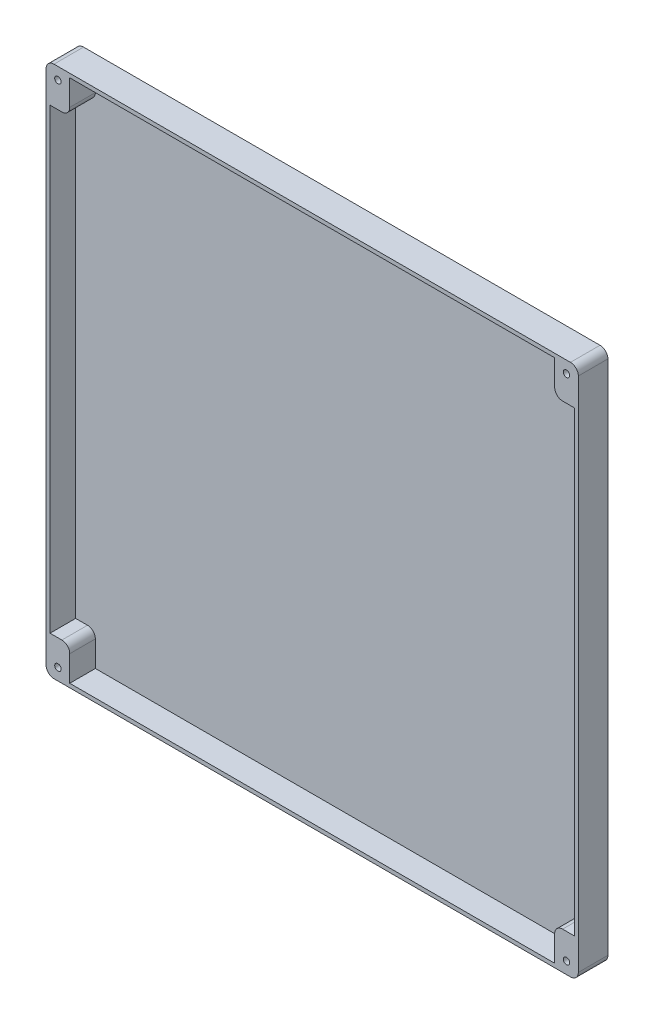
from build123d import *

# Parameters (mm, degrees)
ESQUISSE1_W                                  = 270
ESQUISSE1_H                                  = 270
EXTRUSION1_DEPTH                             = 15
CONG_2_R                                     = 4
EXTRUSION2_DEPTH                             = 13
CONG_3_R                                     = 4
CHAMBRAGE_POUR_VIS_T_TE_RONDE_BOMB_E_A_COUNT = 2
CHAMBRAGE_POUR_VIS_T_TE_RONDE_BOMB_E_A_PITCH = 258
CHAMBRAGE_POUR_VIS_T_TE_RONDE_BOMB_2_COUNT   = 2
CHAMBRAGE_POUR_VIS_T_TE_RONDE_BOMB_2_PITCH   = 364.867099092
CHAMBRAGE_POUR_VIS_T_TE_RONDE_BOMB_3_COUNT   = 2
CHAMBRAGE_POUR_VIS_T_TE_RONDE_BOMB_3_PITCH   = 258


with BuildPart() as part:
    # Esquisse1 → Extrusion1 (new body)
    with BuildSketch(Plane.XY):
        with Locations((135, -135)):
            Rectangle(ESQUISSE1_W, ESQUISSE1_H)
    extrude(amount=EXTRUSION1_DEPTH)

    # Congé2
    cong_2_edges = [part.edges().sort_by_distance(p)[0] for p in [
        (0, 0, 7.5),
        (270, 0, 7.5),
        (270, -270, 7.5),
        (0, -270, 7.5),
    ]]
    fillet(cong_2_edges, radius=CONG_2_R)

    # Esquisse2 → Extrusion2 (cut)
    with BuildSketch(Plane.XY.offset(15)):
        Polygon((12, -2), (12, -19), (2, -19), (2, -251), (12, -251), (12, -268), (258, -268), (258, -251), (268, -251), (268, -19), (258, -19), (258, -2), align=None)
    extrude(amount=-EXTRUSION2_DEPTH, mode=Mode.SUBTRACT)

    # Congé3
    cong_3_edges = [part.edges().sort_by_distance(p)[0] for p in [
        (258, -19, 8.5),
        (258, -251, 8.5),
        (12, -251, 8.5),
        (12, -19, 8.5),
    ]]
    fillet(cong_3_edges, radius=CONG_3_R)

    # Esquisse6 → Chambrage pour vis à tête ronde bombée #41 (revolve, cut)
    with BuildSketch(Plane(origin=(264, -6, 0), x_dir=(0, 1, 0), z_dir=(1, 0, 0))):
        Polygon((0, 0), (0, 15), (1.63195, 15), (1.63195, 4.031996), (3.175, 4.031996), (3.175, 0.635), (3.81, 0), align=None)
    chambrage_pour_vis_t_te_ronde_bomb_e = revolve(axis=Axis((264, -6, -6.35), (0, 0, 1)), mode=Mode.SUBTRACT)

    # Chambrage pour vis à tête ronde bombée #41 a: Chambrage pour vis à tête ronde bombée #41 ×2
    with Locations(*[(-i * CHAMBRAGE_POUR_VIS_T_TE_RONDE_BOMB_E_A_PITCH, 0, 0) for i in range(1, CHAMBRAGE_POUR_VIS_T_TE_RONDE_BOMB_E_A_COUNT)]):
        add(chambrage_pour_vis_t_te_ronde_bomb_e, mode=Mode.SUBTRACT)

    # Chambrage pour vis _ t_te ronde bomb 2: Chambrage pour vis à tête ronde bombée #41 ×2
    with Locations(*[Vector(-0.707106781, -0.707106781, 0) * (i * CHAMBRAGE_POUR_VIS_T_TE_RONDE_BOMB_2_PITCH) for i in range(1, CHAMBRAGE_POUR_VIS_T_TE_RONDE_BOMB_2_COUNT)]):
        add(chambrage_pour_vis_t_te_ronde_bomb_e, mode=Mode.SUBTRACT)

    # Chambrage pour vis _ t_te ronde bomb 3: Chambrage pour vis à tête ronde bombée #41 ×2
    with Locations(*[(0, -i * CHAMBRAGE_POUR_VIS_T_TE_RONDE_BOMB_3_PITCH, 0) for i in range(1, CHAMBRAGE_POUR_VIS_T_TE_RONDE_BOMB_3_COUNT)]):
        add(chambrage_pour_vis_t_te_ronde_bomb_e, mode=Mode.SUBTRACT)


solid = part.part
